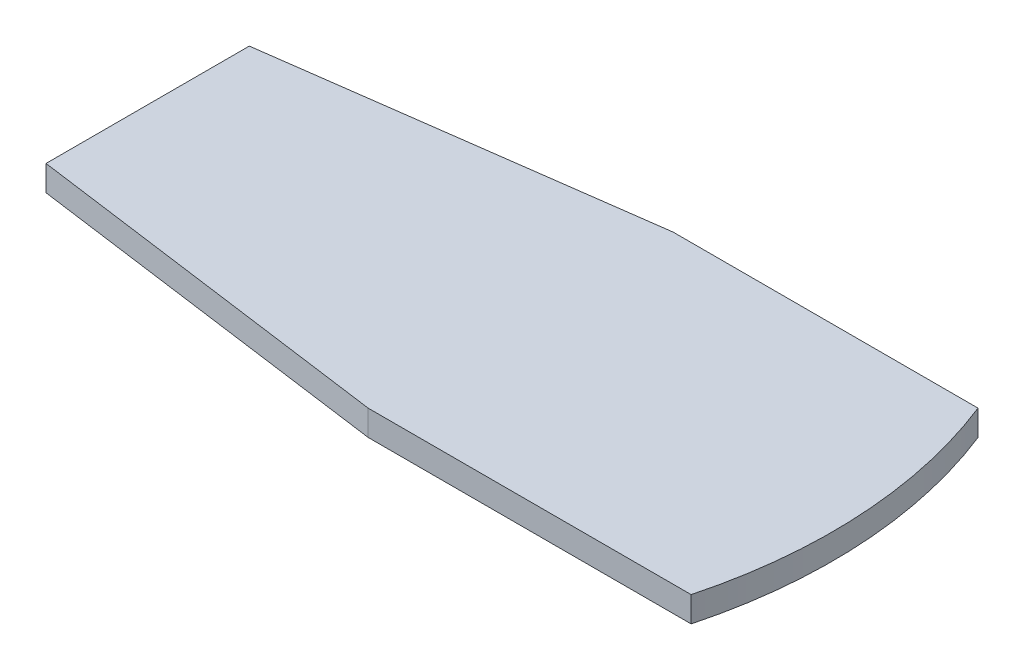
from build123d import *

# Parameters (mm, degrees)
BOSS_EXTRUDE1_DEPTH = 3.175


with BuildPart() as part:
    # Sketch1 → Boss-Extrude1 (new body)
    with BuildSketch(Plane(origin=(0, 0, 0), x_dir=(1, 0, 0), z_dir=(0, 1, 0))):
        with BuildLine():
            Line((-4.202954503, 19.05), (-42.302954503, 19.05))
            Line((-42.302954503, 19.05), (-88.9, 12.7))
            Line((-88.9, 12.7), (-88.9, -12.7))
            Line((-88.9, -12.7), (-42.302954503, -19.05))
            Line((-42.302954503, -19.05), (-1.945497784, -19.05))
            ThreePointArc((-1.945497784, -19.05), (-0.010483672, 0.181529292), (-4.202954503, 19.05))
        make_face()
    extrude(amount=-BOSS_EXTRUDE1_DEPTH)


solid = part.part
